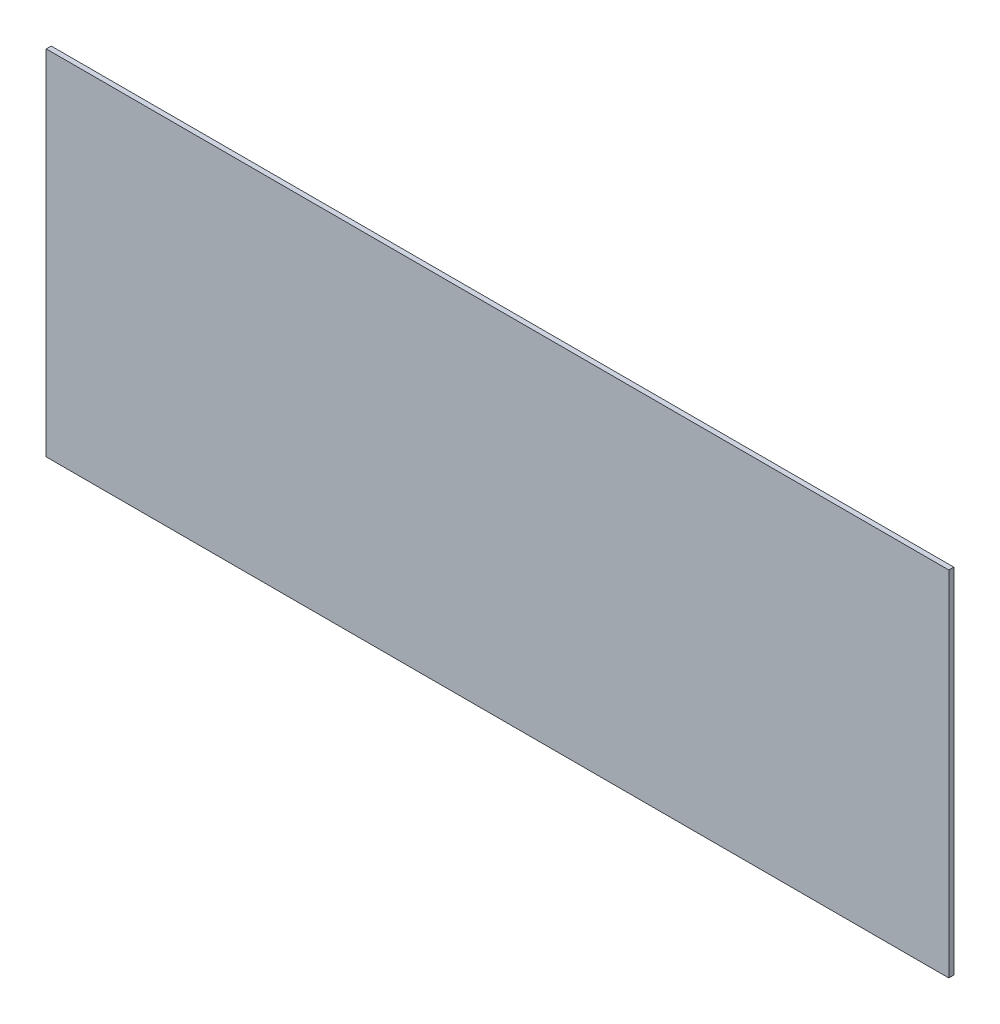
from build123d import *

# Parameters (mm, degrees)
SKETCH1_W           = 23.008
SKETCH1_H           = 9.008
BOSS_EXTRUDE1_DEPTH = 0.127


with BuildPart() as part:
    # Sketch1 → Boss-Extrude1 (new body)
    with BuildSketch(Plane.XY):
        with Locations((3082.138757164, 1134.305694712)):
            Rectangle(SKETCH1_W, SKETCH1_H)
    extrude(amount=BOSS_EXTRUDE1_DEPTH)


solid = part.part
